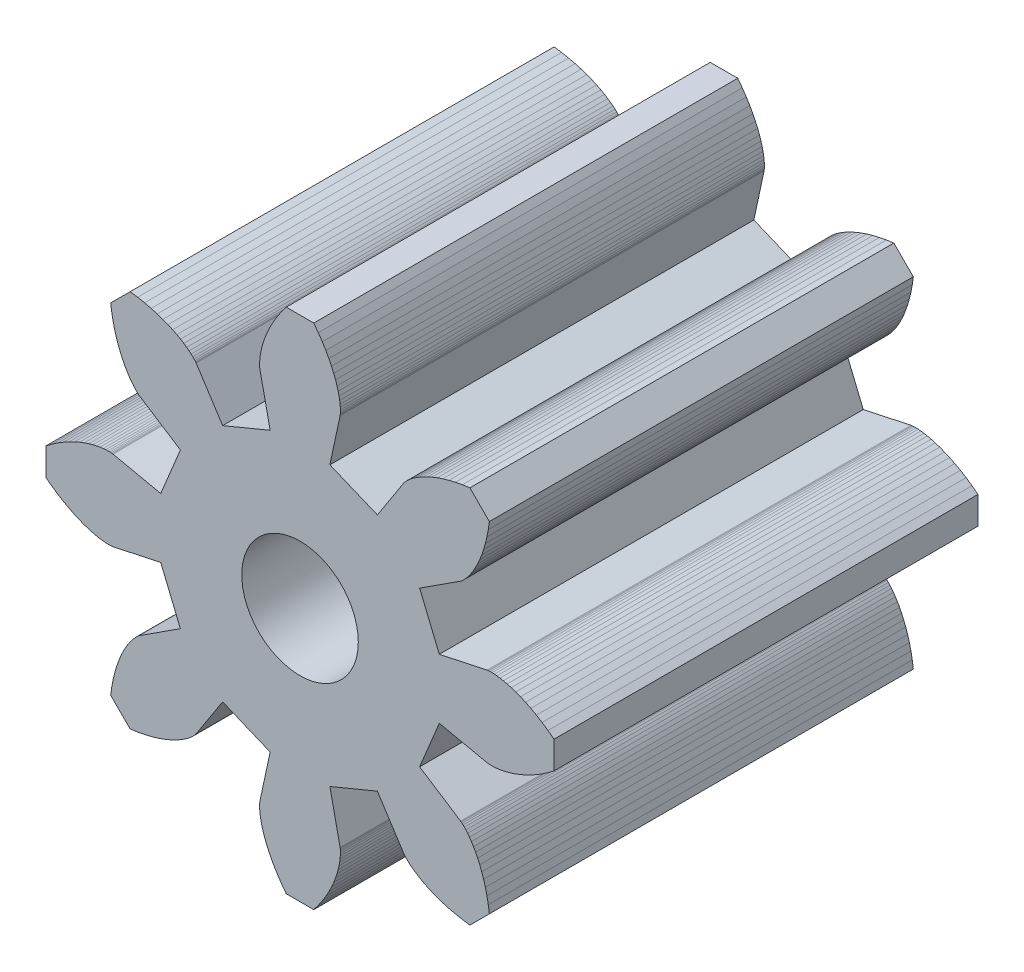
from build123d import *

# Parameters (mm, degrees)
BOSS_EXTRUDE1_DEPTH = 6
SKETCH5_R           = 1.65
CUT_EXTRUDE1_DEPTH  = 10


with BuildPart() as part:
    # Model → Boss-Extrude1 (new body, symmetric)
    with BuildSketch(Plane.XY):
        Polygon((3.942363645, 0.845454252), (5.292300036, 1.134953031), (5.297974665, 1.135988423), (5.315111204, 1.138393476), (5.343823835, 1.141108928), (5.384153257, 1.143069026), (5.436066383, 1.14320605), (5.499456299, 1.140454862), (5.574142481, 1.133757442), (5.65987128, 1.122067408), (5.756316661, 1.104354512), (5.863081206, 1.079609078), (5.979697367, 1.046846393), (6.105628975, 1.005111008), (6.240272999, 0.953480969), (6.382961537, 0.891071929), (6.53296406, 0.817041154), (6.689489871, 0.730591399), (6.851690797, 0.630974643), (7.018664092, 0.517495669), (7.18945555, 0.389515477), (7.18945555, -0.389515477), (7.018664092, -0.517495669), (6.851690797, -0.630974643), (6.689489871, -0.730591399), (6.53296406, -0.817041154), (6.382961537, -0.891071929), (6.240272999, -0.953480969), (6.105628975, -1.005111008), (5.979697367, -1.046846393), (5.863081206, -1.079609078), (5.756316661, -1.104354512), (5.65987128, -1.122067408), (5.574142481, -1.133757442), (5.499456299, -1.140454862), (5.436066383, -1.14320605), (5.384153257, -1.143069026), (5.343823835, -1.141108928), (5.315111204, -1.138393476), (5.297974665, -1.135988423), (5.292300036, -1.134953031), (3.942363645, -0.845454252), (3.385498502, -2.189845632), (4.544754228, -2.939688259), (4.549498929, -2.942968695), (4.563316921, -2.953385429), (4.585539932, -2.97176821), (4.615443138, -2.998899419), (4.652248153, -3.035510652), (4.695126209, -3.082279475), (4.743201523, -3.139826372), (4.795554836, -3.208711889), (4.85122711, -3.289433982), (4.90922338, -3.382425579), (4.968516741, -3.488052374), (5.028052462, -3.606610842), (5.086752213, -3.738326495), (5.143518391, -3.883352383), (5.197238529, -4.041767848), (5.246789783, -4.213577518), (5.291043474, -4.398710576), (5.328869671, -4.597020278), (5.359141808, -4.808283737), (4.808283737, -5.359141808), (4.597020278, -5.328869671), (4.398710576, -5.291043474), (4.213577518, -5.246789783), (4.041767848, -5.197238529), (3.883352383, -5.143518391), (3.738326495, -5.086752213), (3.606610842, -5.028052462), (3.488052374, -4.968516741), (3.382425579, -4.90922338), (3.289433982, -4.85122711), (3.208711889, -4.795554836), (3.139826372, -4.743201523), (3.082279475, -4.695126209), (3.035510652, -4.652248153), (2.998899419, -4.615443138), (2.97176821, -4.585539932), (2.953385429, -4.563316921), (2.942968695, -4.549498929), (2.939688259, -4.544754228), (2.189845632, -3.385498502), (0.845454252, -3.942363645), (1.134953031, -5.292300036), (1.135988423, -5.297974665), (1.138393476, -5.315111204), (1.141108928, -5.343823835), (1.143069026, -5.384153257), (1.14320605, -5.436066383), (1.140454862, -5.499456299), (1.133757442, -5.574142481), (1.122067408, -5.65987128), (1.104354512, -5.756316661), (1.079609078, -5.863081206), (1.046846393, -5.979697367), (1.005111008, -6.105628975), (0.953480969, -6.240272999), (0.891071929, -6.382961537), (0.817041154, -6.53296406), (0.730591399, -6.689489871), (0.630974643, -6.851690797), (0.517495669, -7.018664092), (0.389515477, -7.18945555), (-0.389515477, -7.18945555), (-0.517495669, -7.018664092), (-0.630974643, -6.851690797), (-0.730591399, -6.689489871), (-0.817041154, -6.53296406), (-0.891071929, -6.382961537), (-0.953480969, -6.240272999), (-1.005111008, -6.105628975), (-1.046846393, -5.979697367), (-1.079609078, -5.863081206), (-1.104354512, -5.756316661), (-1.122067408, -5.65987128), (-1.133757442, -5.574142481), (-1.140454862, -5.499456299), (-1.14320605, -5.436066383), (-1.143069026, -5.384153257), (-1.141108928, -5.343823835), (-1.138393476, -5.315111204), (-1.135988423, -5.297974665), (-1.134953031, -5.292300036), (-0.845454252, -3.942363645), (-2.189845632, -3.385498502), (-2.939688259, -4.544754228), (-2.942968695, -4.549498929), (-2.953385429, -4.563316921), (-2.97176821, -4.585539932), (-2.998899419, -4.615443138), (-3.035510652, -4.652248153), (-3.082279475, -4.695126209), (-3.139826372, -4.743201523), (-3.208711889, -4.795554836), (-3.289433982, -4.85122711), (-3.382425579, -4.90922338), (-3.488052374, -4.968516741), (-3.606610842, -5.028052462), (-3.738326495, -5.086752213), (-3.883352383, -5.143518391), (-4.041767848, -5.197238529), (-4.213577518, -5.246789783), (-4.398710576, -5.291043474), (-4.597020278, -5.328869671), (-4.808283737, -5.359141808), (-5.359141808, -4.808283737), (-5.328869671, -4.597020278), (-5.291043474, -4.398710576), (-5.246789783, -4.213577518), (-5.197238529, -4.041767848), (-5.143518391, -3.883352383), (-5.086752213, -3.738326495), (-5.028052462, -3.606610842), (-4.968516741, -3.488052374), (-4.90922338, -3.382425579), (-4.85122711, -3.289433982), (-4.795554836, -3.208711889), (-4.743201523, -3.139826372), (-4.695126209, -3.082279475), (-4.652248153, -3.035510652), (-4.615443138, -2.998899419), (-4.585539932, -2.97176821), (-4.563316921, -2.953385429), (-4.549498929, -2.942968695), (-4.544754228, -2.939688259), (-3.385498502, -2.189845632), (-3.942363645, -0.845454252), (-5.292300036, -1.134953031), (-5.297974665, -1.135988423), (-5.315111204, -1.138393476), (-5.343823835, -1.141108928), (-5.384153257, -1.143069026), (-5.436066383, -1.14320605), (-5.499456299, -1.140454862), (-5.574142481, -1.133757442), (-5.65987128, -1.122067408), (-5.756316661, -1.104354512), (-5.863081206, -1.079609078), (-5.979697367, -1.046846393), (-6.105628975, -1.005111008), (-6.240272999, -0.953480969), (-6.382961537, -0.891071929), (-6.53296406, -0.817041154), (-6.689489871, -0.730591399), (-6.851690797, -0.630974643), (-7.018664092, -0.517495669), (-7.18945555, -0.389515477), (-7.18945555, 0.389515477), (-7.018664092, 0.517495669), (-6.851690797, 0.630974643), (-6.689489871, 0.730591399), (-6.53296406, 0.817041154), (-6.382961537, 0.891071929), (-6.240272999, 0.953480969), (-6.105628975, 1.005111008), (-5.979697367, 1.046846393), (-5.863081206, 1.079609078), (-5.756316661, 1.104354512), (-5.65987128, 1.122067408), (-5.574142481, 1.133757442), (-5.499456299, 1.140454862), (-5.436066383, 1.14320605), (-5.384153257, 1.143069026), (-5.343823835, 1.141108928), (-5.315111204, 1.138393476), (-5.297974665, 1.135988423), (-5.292300036, 1.134953031), (-3.942363645, 0.845454252), (-3.385498502, 2.189845632), (-4.544754228, 2.939688259), (-4.549498929, 2.942968695), (-4.563316921, 2.953385429), (-4.585539932, 2.97176821), (-4.615443138, 2.998899419), (-4.652248153, 3.035510652), (-4.695126209, 3.082279475), (-4.743201523, 3.139826372), (-4.795554836, 3.208711889), (-4.85122711, 3.289433982), (-4.90922338, 3.382425579), (-4.968516741, 3.488052374), (-5.028052462, 3.606610842), (-5.086752213, 3.738326495), (-5.143518391, 3.883352383), (-5.197238529, 4.041767848), (-5.246789783, 4.213577518), (-5.291043474, 4.398710576), (-5.328869671, 4.597020278), (-5.359141808, 4.808283737), (-4.808283737, 5.359141808), (-4.597020278, 5.328869671), (-4.398710576, 5.291043474), (-4.213577518, 5.246789783), (-4.041767848, 5.197238529), (-3.883352383, 5.143518391), (-3.738326495, 5.086752213), (-3.606610842, 5.028052462), (-3.488052374, 4.968516741), (-3.382425579, 4.90922338), (-3.289433982, 4.85122711), (-3.208711889, 4.795554836), (-3.139826372, 4.743201523), (-3.082279475, 4.695126209), (-3.035510652, 4.652248153), (-2.998899419, 4.615443138), (-2.97176821, 4.585539932), (-2.953385429, 4.563316921), (-2.942968695, 4.549498929), (-2.939688259, 4.544754228), (-2.189845632, 3.385498502), (-0.845454252, 3.942363645), (-1.134953031, 5.292300036), (-1.135988423, 5.297974665), (-1.138393476, 5.315111204), (-1.141108928, 5.343823835), (-1.143069026, 5.384153257), (-1.14320605, 5.436066383), (-1.140454862, 5.499456299), (-1.133757442, 5.574142481), (-1.122067408, 5.65987128), (-1.104354512, 5.756316661), (-1.079609078, 5.863081206), (-1.046846393, 5.979697367), (-1.005111008, 6.105628975), (-0.953480969, 6.240272999), (-0.891071929, 6.382961537), (-0.817041154, 6.53296406), (-0.730591399, 6.689489871), (-0.630974643, 6.851690797), (-0.517495669, 7.018664092), (-0.389515477, 7.18945555), (0.389515477, 7.18945555), (0.517495669, 7.018664092), (0.630974643, 6.851690797), (0.730591399, 6.689489871), (0.817041154, 6.53296406), (0.891071929, 6.382961537), (0.953480969, 6.240272999), (1.005111008, 6.105628975), (1.046846393, 5.979697367), (1.079609078, 5.863081206), (1.104354512, 5.756316661), (1.122067408, 5.65987128), (1.133757442, 5.574142481), (1.140454862, 5.499456299), (1.14320605, 5.436066383), (1.143069026, 5.384153257), (1.141108928, 5.343823835), (1.138393476, 5.315111204), (1.135988423, 5.297974665), (1.134953031, 5.292300036), (0.845454252, 3.942363645), (2.189845632, 3.385498502), (2.939688259, 4.544754228), (2.942968695, 4.549498929), (2.953385429, 4.563316921), (2.97176821, 4.585539932), (2.998899419, 4.615443138), (3.035510652, 4.652248153), (3.082279475, 4.695126209), (3.139826372, 4.743201523), (3.208711889, 4.795554836), (3.289433982, 4.85122711), (3.382425579, 4.90922338), (3.488052374, 4.968516741), (3.606610842, 5.028052462), (3.738326495, 5.086752213), (3.883352383, 5.143518391), (4.041767848, 5.197238529), (4.213577518, 5.246789783), (4.398710576, 5.291043474), (4.597020278, 5.328869671), (4.808283737, 5.359141808), (5.359141808, 4.808283737), (5.328869671, 4.597020278), (5.291043474, 4.398710576), (5.246789783, 4.213577518), (5.197238529, 4.041767848), (5.143518391, 3.883352383), (5.086752213, 3.738326495), (5.028052462, 3.606610842), (4.968516741, 3.488052374), (4.90922338, 3.382425579), (4.85122711, 3.289433982), (4.795554836, 3.208711889), (4.743201523, 3.139826372), (4.695126209, 3.082279475), (4.652248153, 3.035510652), (4.615443138, 2.998899419), (4.585539932, 2.97176821), (4.563316921, 2.953385429), (4.549498929, 2.942968695), (4.544754228, 2.939688259), (3.385498502, 2.189845632), align=None)
    extrude(amount=BOSS_EXTRUDE1_DEPTH, both=True)

    # Sketch5 → Cut-Extrude1 (cut)
    with BuildSketch(Plane.XY.offset(6)):
        Circle(SKETCH5_R)
    extrude(amount=-CUT_EXTRUDE1_DEPTH, mode=Mode.SUBTRACT)


solid = part.part
